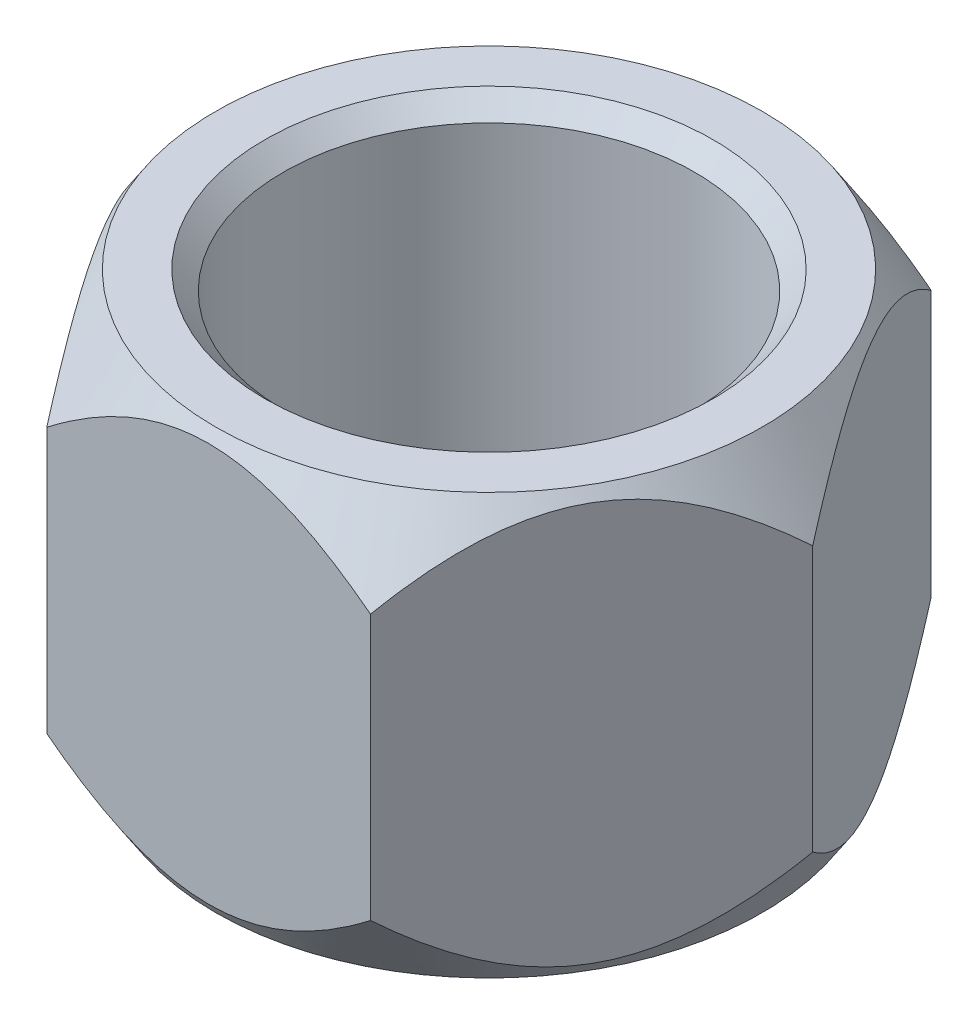
from build123d import *

# Parameters (mm, degrees)
EXTRUDE_1_DEPTH     = 22.5
SKETCH_2_R          = 11
CUT_EXTRUDE_2_DEPTH = 18
CUT_EXTRUDE_3_REACH = 24.5
SKETCH_3_R          = 4
CHAMFER_1_SIZE      = 1


with BuildPart() as part:
    # Эскиз1 → Бобышка-Вытянуть1 (new body)
    with BuildSketch(Plane(origin=(0, 0, 0), x_dir=(1, 0, 0), z_dir=(0, 1, 0))):
        Polygon((17.320508076, 0), (8.660254038, 15), (-8.660254038, 15), (-17.320508076, 0), (-8.660254038, -15), (8.660254038, -15), align=None)
    extrude(amount=EXTRUDE_1_DEPTH)

    # Эскиз2 → Вырез-Вытянуть2 (cut)
    with BuildSketch(Plane(origin=(0, 22.5, 0), x_dir=(1, 0, 0), z_dir=(0, 1, 0))):
        Circle(SKETCH_2_R)
    extrude(amount=-CUT_EXTRUDE_2_DEPTH, mode=Mode.SUBTRACT)

    # Эскиз3 → Вырез-Вытянуть3 (cut, up to next)
    with BuildSketch(Plane.XZ, mode=Mode.PRIVATE) as cut_extrude_3_sk1:
        Circle(SKETCH_3_R)
    cut_extrude_3_tool1 = extrude(cut_extrude_3_sk1.sketch, amount=-CUT_EXTRUDE_3_REACH, mode=Mode.PRIVATE) & part.part
    add(cut_extrude_3_tool1.solids().sort_by_distance((0, 0, 0))[0], mode=Mode.SUBTRACT)

    # Эскиз4 → Вырез-Повернуть1 (revolve, cut)
    with BuildSketch(Plane(origin=(0, 0, 0), x_dir=(-0.5, 0, 0.866025404), z_dir=(-0.866025404, 0, -0.5))):
        Polygon((-17.320508076, 18.345818937), (-17.320508076, 22.5), (-14.628303654, 22.5), align=None)
    cut_revolve_1 = revolve(axis=Axis((0, 0, 0), (0, 1, 0)), mode=Mode.SUBTRACT)

    # Зеркальное отражение1: Вырез-Повернуть1 across plane
    add(cut_revolve_1.mirror(Plane.ZX.offset(11.25)), mode=Mode.SUBTRACT)

    # Фаска1
    chamfer_1_edges = [part.edges().sort_by_distance(p)[0] for p in [
        (-11, 22.5, 0),
    ]]
    chamfer(chamfer_1_edges, length=CHAMFER_1_SIZE)


solid = part.part
